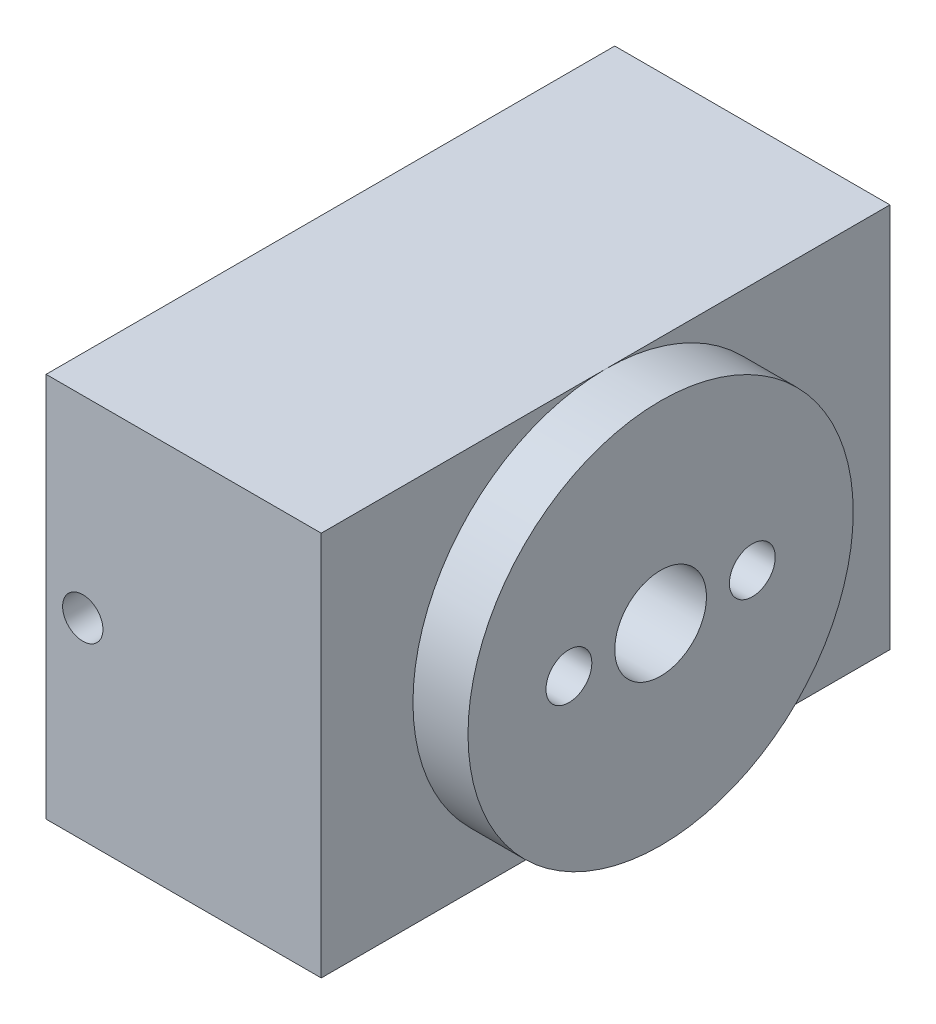
from build123d import *

# Parameters (mm, degrees)
SKETCH1_W               = 31
SKETCH1_H               = 21
BOSS_EXTRUDE1_DEPTH     = 15
M2_CLEARANCE_HOLE1_D    = 2.2
SKETCH10_R              = 10.5
BOSS_EXTRUDE3_DEPTH     = 3
SKETCH7_R               = 1.25
SKETCH7_R_2             = 2.5
CUT_EXTRUDE1_DEPTH      = 4
CUT_EXTRUDE1_DEPTH_BACK = 16


with BuildPart() as part:
    # Sketch1 → Boss-Extrude1 (new body)
    with BuildSketch(Plane(origin=(0, 0, 0), x_dir=(0, 0, -1), z_dir=(1, 0, 0))):
        Rectangle(SKETCH1_W, SKETCH1_H)
    extrude(amount=BOSS_EXTRUDE1_DEPTH)

    # M2 Clearance Hole1 (through all)
    with Locations(Plane.XY.offset(15.5)):
        with Locations((2, 0)):
            Hole(M2_CLEARANCE_HOLE1_D / 2)

    # Sketch10 → Boss-Extrude3 (add)
    with BuildSketch(Plane(origin=(15, 0, 0), x_dir=(0, 0, -1), z_dir=(1, 0, 0))):
        Circle(SKETCH10_R)
    extrude(amount=BOSS_EXTRUDE3_DEPTH)

    # Sketch7 → Cut-Extrude1 (cut, two sides)
    with BuildSketch(Plane(origin=(15, 0, 0), x_dir=(0, 0, -1), z_dir=(1, 0, 0))) as cut_extrude1_sk:
        with Locations((-5, 0)):
            Circle(SKETCH7_R)
        with Locations((5, 0)):
            Circle(SKETCH7_R)
        Circle(SKETCH7_R_2)
    extrude(amount=CUT_EXTRUDE1_DEPTH, mode=Mode.SUBTRACT)
    extrude(cut_extrude1_sk.sketch, amount=-CUT_EXTRUDE1_DEPTH_BACK, mode=Mode.SUBTRACT)


solid = part.part
